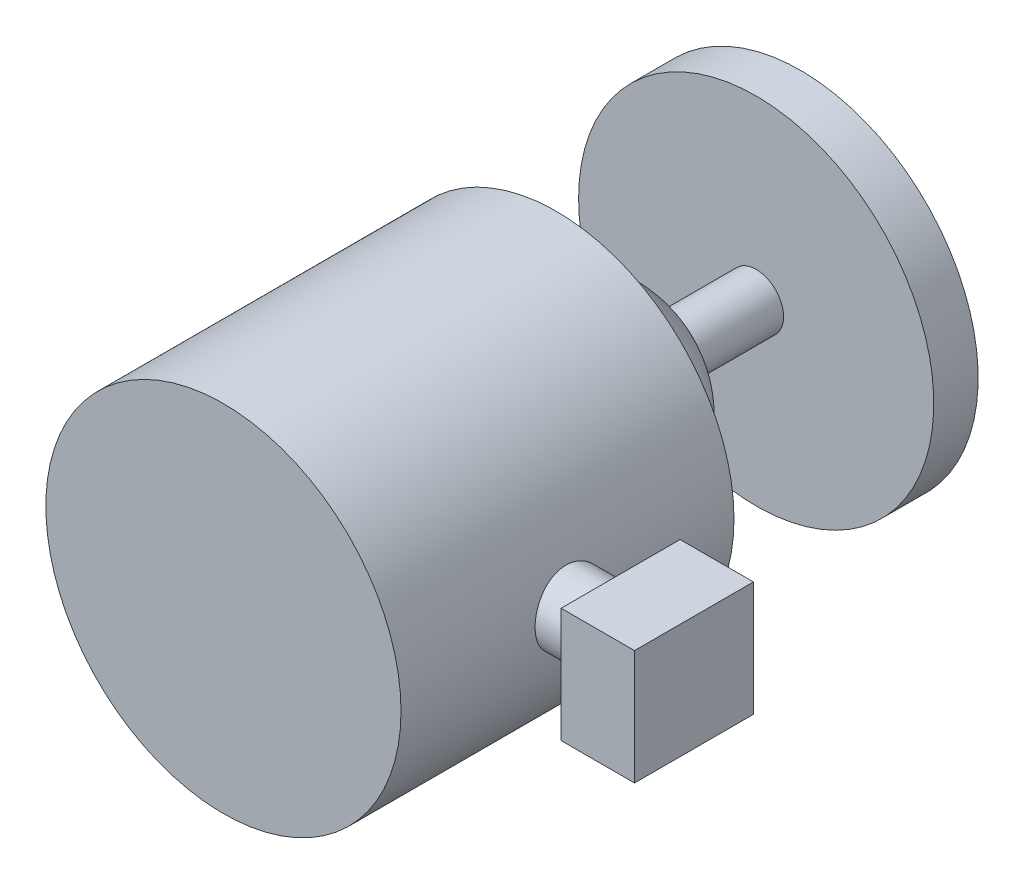
from build123d import *

# Parameters (mm, degrees)
SKETCH1_R               = 16
BOSS_EXTRUDE1_DEPTH     = 30
SKETCH2_R               = 3.175
BOSS_EXTRUDE2_DEPTH     = 20.582030842
SKETCH3_W               = 10.714658548
SKETCH3_H               = 10.331992171
BOSS_EXTRUDE3_DEPTH     = 6.612030842
SKETCH5_R               = 2.469573247
BOSS_EXTRUDE4_DEPTH     = 28
SKETCH6_R               = 16
BOSS_EXTRUDE5_DEPTH     = 10
SKETCH6_2_R             = 16
SKETCH6_2_R_2           = 2.5
CUT_EXTRUDE_THIN1_DEPTH = 6


with BuildPart() as part:
    # Sketch1 → Boss-Extrude1 (new body)
    with BuildSketch(Plane.XY):
        Circle(SKETCH1_R)
    extrude(amount=BOSS_EXTRUDE1_DEPTH)

    # Sketch2 → Boss-Extrude2 (add)
    with BuildSketch(Plane(origin=(0, 0, 0), x_dir=(0, 0, -1), z_dir=(1, 0, 0))):
        with Locations((-14.73814173, 0.386884617)):
            Circle(SKETCH2_R)
    extrude(amount=BOSS_EXTRUDE2_DEPTH)

    # Sketch3 → Boss-Extrude3 (add)
    with BuildSketch(Plane(origin=(20.582030842, 0, 0), x_dir=(0, 0, -1), z_dir=(1, 0, 0))):
        with Locations((-14.79803719, 0.233851674)):
            Rectangle(SKETCH3_W, SKETCH3_H)
    extrude(amount=BOSS_EXTRUDE3_DEPTH)

    # Sketch4 → Revolve1 (revolve)
    with BuildSketch(Plane(origin=(0, 0, 0), x_dir=(-1, 0, 0), z_dir=(0, 0, -1))):
        with BuildLine():
            ThreePointArc((10, 0), (-0.066566913, 9.99977844), (-9.999113769, -0.133130877))
            Line((-9.999113769, -0.133130877), (9.999952802, -0.030723799))
            ThreePointArc((9.999952802, -0.030723799), (9.999988201, -0.015361918), (10, 0))
        make_face()
    revolve(axis=Axis((15.849507962, -0.163088364, 0), (-0.9999868900221045, 0.005120525746398906, 0)))

    # Sketch5 → Boss-Extrude4 (add)
    with BuildSketch(Plane(origin=(0, 0, 0), x_dir=(-1, 0, 0), z_dir=(0, 0, -1))):
        Circle(SKETCH5_R)
    extrude(amount=BOSS_EXTRUDE4_DEPTH)

    # Sketch6 → Boss-Extrude5 (add)
    with BuildSketch(Plane(origin=(0, 0, -28), x_dir=(-1, 0, 0), z_dir=(0, 0, -1))):
        Circle(SKETCH6_R)
    extrude(amount=-BOSS_EXTRUDE5_DEPTH)

    # Sketch6_2 → Cut-Extrude-Thin1 (cut)
    with BuildSketch(Plane(origin=(0, 0, -28), x_dir=(-1, 0, 0), z_dir=(0, 0, -1))):
        Circle(SKETCH6_2_R)
        Circle(SKETCH6_2_R_2, mode=Mode.SUBTRACT)
    extrude(amount=-CUT_EXTRUDE_THIN1_DEPTH, mode=Mode.SUBTRACT)


solid = part.part
